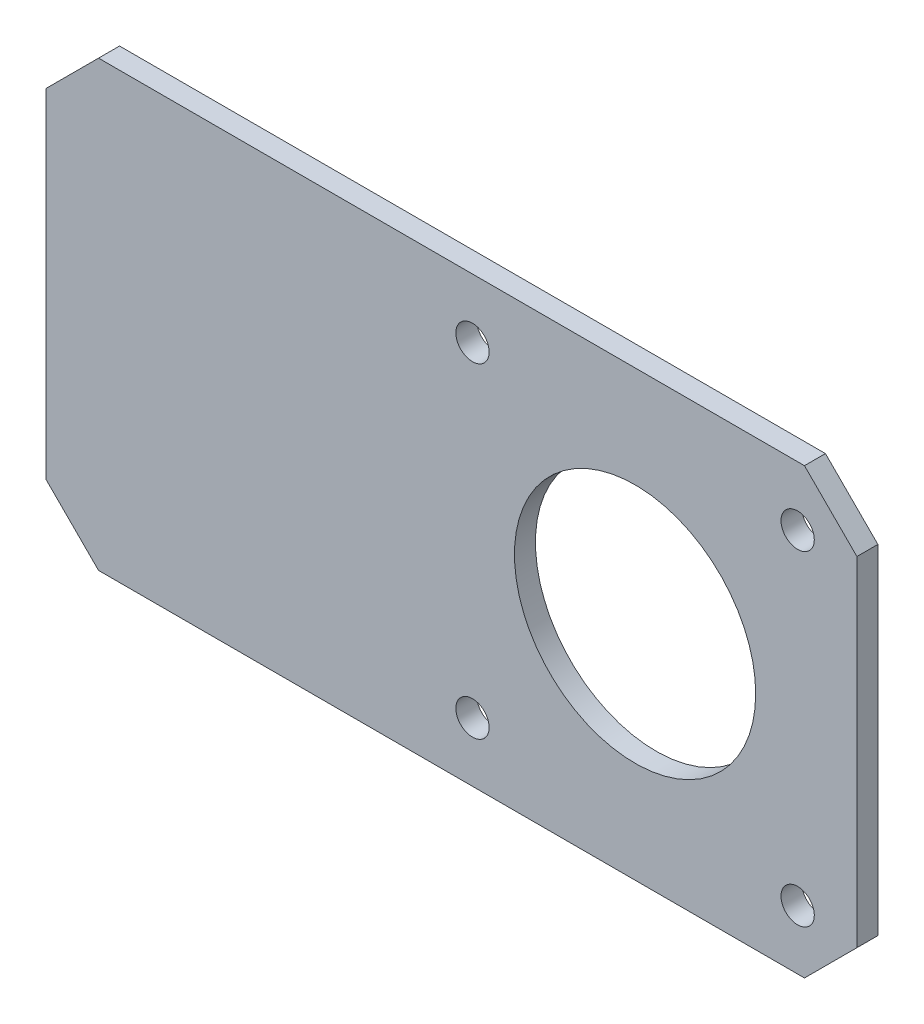
from build123d import *

# Parameters (mm, degrees)
SKETCH1_W                        = 35
SKETCH1_H                        = 42.3
SKETCH1_W_2                      = 42.3
BOSS_EXTRUDE1_DEPTH              = 2
F_1_8_0_125_DIAMETER_HOLE1_D     = 3.175
F_1_8_0_125_DIAMETER_HOLE1_DEPTH = 4.5
F_1_8_0_125_DIAMETER_HOLE1_TIP   = 0.953866233
SKETCH4_R                        = 11.5
CUT_EXTRUDE1_DEPTH               = 2
CHAMFER1_SIZE                    = 5


with BuildPart() as part:
    # Sketch1 → Boss-Extrude1 (new body)
    with BuildSketch(Plane.XY):
        with Locations((-38.65, 0)):
            Rectangle(SKETCH1_W, SKETCH1_H)
        Rectangle(SKETCH1_W_2, SKETCH1_H)
    extrude(amount=BOSS_EXTRUDE1_DEPTH)

    # 1/8 (0.125) Diameter Hole1
    with Locations(Plane.XY.offset(2)):
        with Locations((-15.5, 15.5), (15.5, 15.5), (15.5, -15.5), (-15.5, -15.5)):
            Hole(F_1_8_0_125_DIAMETER_HOLE1_D / 2, depth=F_1_8_0_125_DIAMETER_HOLE1_DEPTH)
            with Locations((0, 0, -(F_1_8_0_125_DIAMETER_HOLE1_DEPTH + F_1_8_0_125_DIAMETER_HOLE1_TIP / 2))):  # 118° drill point
                Cone(0, F_1_8_0_125_DIAMETER_HOLE1_D / 2, F_1_8_0_125_DIAMETER_HOLE1_TIP, mode=Mode.SUBTRACT)

    # Sketch4 → Cut-Extrude1 (cut)
    with BuildSketch(Plane.XY.offset(2)):
        Circle(SKETCH4_R)
    extrude(amount=-CUT_EXTRUDE1_DEPTH, mode=Mode.SUBTRACT)

    # Chamfer1
    chamfer1_edges = [part.edges().sort_by_distance(p)[0] for p in [
        (21.15, 21.15, 1),
        (21.15, -21.15, 1),
        (-56.15, -21.15, 1),
        (-56.15, 21.15, 1),
    ]]
    chamfer(chamfer1_edges, length=CHAMFER1_SIZE)


solid = part.part
